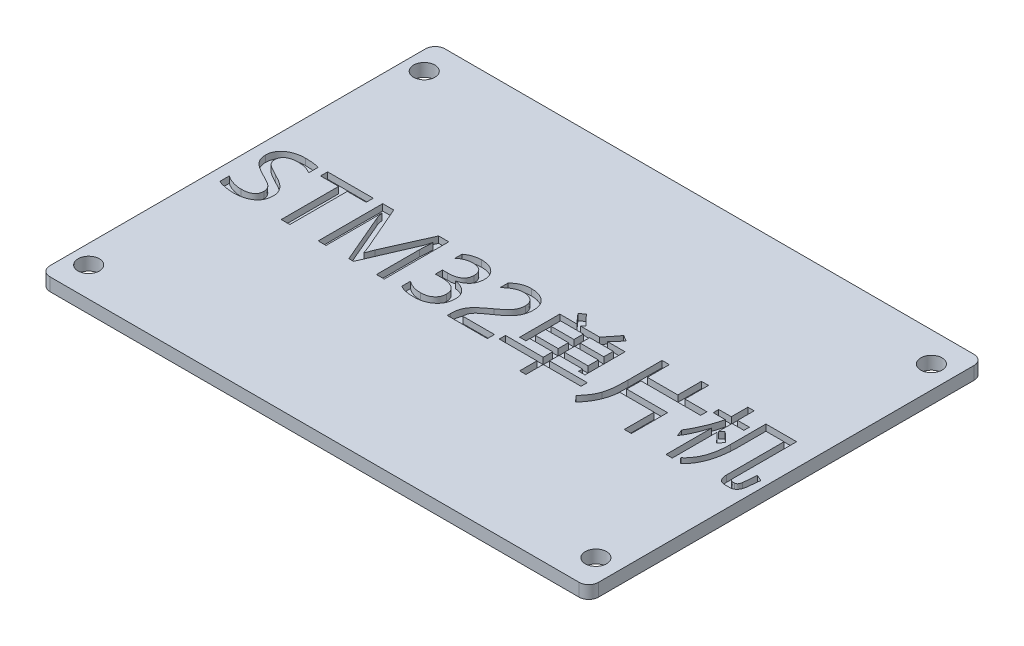
from build123d import *

# Parameters (mm, degrees)
SKETCH_1_R          = 1.65
EXTRUDE_1_DEPTH     = 2
SKETCH_2_W          = 3.658536585
SKETCH_2_H          = 1.585365854
SKETCH_2_W_2        = 3.536585366
SKETCH_2_H_2        = 1.463414634
CUT_EXTRUDE_1_DEPTH = 1


with BuildPart() as part:
    # 草图1 → 凸台-拉伸1 (new body)
    with BuildSketch(Plane(origin=(0, 0, 0), x_dir=(1, 0, 0), z_dir=(0, 1, 0))):
        with BuildLine():
            Line((41, -30.6), (-41, -30.6))
            ThreePointArc((-41, -30.6), (-42.060660172, -30.160660172), (-42.5, -29.1))
            Line((-42.5, -29.1), (-42.5, 29.1))
            ThreePointArc((-42.5, 29.1), (-42.060660172, 30.160660172), (-41, 30.6))
            Line((-41, 30.6), (41, 30.6))
            ThreePointArc((41, 30.6), (42.060660172, 30.160660172), (42.5, 29.1))
            Line((42.5, 29.1), (42.5, -29.1))
            ThreePointArc((42.5, -29.1), (42.060660172, -30.160660172), (41, -30.6))
        make_face()
        with Locations((-39.6, 26)):
            Circle(SKETCH_1_R, mode=Mode.SUBTRACT)
        with Locations((-39.6, -26)):
            Circle(SKETCH_1_R, mode=Mode.SUBTRACT)
        with Locations((39, 26)):
            Circle(SKETCH_1_R, mode=Mode.SUBTRACT)
        with Locations((39, -26)):
            Circle(SKETCH_1_R, mode=Mode.SUBTRACT)
    extrude(amount=EXTRUDE_1_DEPTH)

    # 草图2 → 切除-拉伸1 (cut)
    with BuildSketch(Plane(origin=(0, 2, 0), x_dir=(1, 0, 0), z_dir=(0, 1, 0))):
        with BuildLine():
            add(Edge.make_bspline(
                [(-40.646341463, -3.140243902), (-40.565092815, -3.203754718), (-40.397162723, -3.335023081), (-40.108905464, -3.501725879), (-39.78390449, -3.651656733), (-39.427947104, -3.781522664), (-39.05876287, -3.888750607), (-38.690356576, -3.964438153), (-38.332613597, -4.015677413), (-38.096329633, -4.021525175), (-37.980564024, -4.024390244)],
                knots=[0, 0, 0, 0, 0.000309071, 0.000638809, 0.00099601, 0.001381842, 0.001774451, 0.00214816, 0.002509545, 0.002856679, 0.002856679, 0.002856679, 0.002856679], degree=3))
            add(Edge.make_bspline(
                [(-37.980564024, -4.024390244), (-37.896064471, -4.023309527), (-37.73259623, -4.021218832), (-37.495124829, -4.004703541), (-37.27457998, -3.973588902), (-37.069965285, -3.934556547), (-36.881531596, -3.883571675), (-36.709580132, -3.8184161), (-36.552730232, -3.742816279), (-36.41237993, -3.65503561), (-36.289239167, -3.554840575), (-36.18150847, -3.444195838), (-36.091088668, -3.321092733), (-36.01789439, -3.185620713), (-35.961519557, -3.038719899), (-35.918730723, -2.880576243), (-35.893962839, -2.71039147), (-35.891506294, -2.592814705), (-35.890243902, -2.532393293)],
                knots=[0, 0, 0, 0, 0.000253494, 0.000490396, 0.000713526, 0.000921302, 0.001114998, 0.001298321, 0.00147217, 0.001636584, 0.001793715, 0.00194734, 0.002098643, 0.002250414, 0.002407879, 0.002569655, 0.002741043, 0.002922225, 0.002922225, 0.002922225, 0.002922225], degree=3))
            add(Edge.make_bspline(
                [(-35.890243902, -2.532393293), (-35.892525252, -2.464193646), (-35.897005818, -2.330249679), (-35.940963971, -2.13495639), (-36.011232602, -1.950078177), (-36.112871236, -1.778177878), (-36.236051123, -1.614951556), (-36.380847803, -1.461470071), (-36.546523643, -1.316911171), (-36.703451022, -1.206127813), (-36.847417041, -1.116201749), (-36.976898627, -1.037390398), (-37.128948402, -0.953100999), (-37.301601501, -0.858880641), (-37.496084605, -0.7561824), (-37.712096543, -0.644489552), (-37.949649275, -0.523795593), (-38.115159744, -0.441320878), (-38.20160061, -0.398246951)],
                knots=[0, 0, 0, 0, 0.000204323, 0.00040129, 0.000597333, 0.000795394, 0.000998138, 0.001209785, 0.001427219, 0.001656702, 0.001785163, 0.001936467, 0.002111367, 0.002306631, 0.002526548, 0.002771141, 0.003036169, 0.003325903, 0.003325903, 0.003325903, 0.003325903], degree=3))
            add(Edge.make_bspline(
                [(-38.20160061, -0.398246951), (-38.321413025, -0.337401977), (-38.552014603, -0.220294355), (-38.878066459, -0.039172921), (-39.172018264, 0.137658693), (-39.434702769, 0.310900845), (-39.665215196, 0.482489378), (-39.866373721, 0.648393833), (-40.033428417, 0.813432757), (-40.172428858, 0.975285656), (-40.2835505, 1.141690383), (-40.382355247, 1.309382063), (-40.463424348, 1.484641217), (-40.530904716, 1.664749203), (-40.582601766, 1.850291602), (-40.617974377, 2.041654783), (-40.642227226, 2.238331735), (-40.644959722, 2.371623007), (-40.646341463, 2.43902439)],
                knots=[0, 0, 0, 0, 0.000403104, 0.00077585, 0.001118652, 0.001432046, 0.001719396, 0.001980447, 0.002213549, 0.002423126, 0.002619206, 0.002813014, 0.003006522, 0.003197651, 0.00338951, 0.003583468, 0.003781061, 0.003983186, 0.003983186, 0.003983186, 0.003983186], degree=3))
            add(Edge.make_bspline(
                [(-40.646341463, 2.43902439), (-40.643766103, 2.539594107), (-40.638731283, 2.736207562), (-40.588931134, 3.022548528), (-40.511607036, 3.29370703), (-40.400195209, 3.54842188), (-40.257584542, 3.786839099), (-40.084456207, 4.00970024), (-39.879277735, 4.216578969), (-39.642706957, 4.402873339), (-39.384660616, 4.572351656), (-39.106939905, 4.718228918), (-38.814841679, 4.845978701), (-38.504552764, 4.945015052), (-38.179724932, 5.026942495), (-37.837111043, 5.079946424), (-37.47891765, 5.115892832), (-37.234341564, 5.119906621), (-37.109756098, 5.12195122)],
                knots=[0, 0, 0, 0, 0.000301453, 0.000589339, 0.000869141, 0.001145621, 0.001420777, 0.00170054, 0.001990231, 0.00229258, 0.002602284, 0.002915121, 0.003232629, 0.003557419, 0.003891091, 0.004236621, 0.004596491, 0.004970141, 0.004970141, 0.004970141, 0.004970141], degree=3))
            add(Edge.make_bspline(
                [(-37.109756098, 5.12195122), (-36.989057483, 5.121488508), (-36.75647164, 5.120596863), (-36.419761549, 5.106269432), (-36.107580242, 5.08675997), (-35.820400358, 5.055853646), (-35.558076698, 5.019180351), (-35.321221261, 4.97051321), (-35.107472183, 4.918298435), (-34.976533877, 4.870267231), (-34.914634146, 4.847560976)],
                knots=[0, 0, 0, 0, 0.000362063, 0.000697694, 0.001010896, 0.001300235, 0.001564054, 0.001805089, 0.002025542, 0.002223199, 0.002223199, 0.002223199, 0.002223199], degree=3))
            Line((-34.914634146, 4.847560976), (-34.914634146, 3.384146341))
            add(Edge.make_bspline(
                [(-34.914634146, 3.384146341), (-34.991763566, 3.435995535), (-35.147236384, 3.540510002), (-35.400514973, 3.667658694), (-35.665992663, 3.779925293), (-35.947689339, 3.868456562), (-36.243584534, 3.939759236), (-36.554661298, 3.987715937), (-36.880420231, 4.019877291), (-37.102687228, 4.022862266), (-37.216463415, 4.024390244)],
                knots=[0, 0, 0, 0, 0.000278553, 0.000561491, 0.000848487, 0.001142562, 0.001446211, 0.001760732, 0.002086097, 0.002427312, 0.002427312, 0.002427312, 0.002427312], degree=3))
            add(Edge.make_bspline(
                [(-37.216463415, 4.024390244), (-37.29146859, 4.023583296), (-37.43855817, 4.022000822), (-37.653982901, 4.001028754), (-37.859346452, 3.974546457), (-38.053651623, 3.932099459), (-38.236827917, 3.87649597), (-38.410409181, 3.810344858), (-38.5729348, 3.731925896), (-38.723660407, 3.6432583), (-38.85910775, 3.542309741), (-38.978337949, 3.431374833), (-39.079622132, 3.311238974), (-39.163836349, 3.181926091), (-39.225653121, 3.041789193), (-39.272862968, 2.893188266), (-39.299012324, 2.734657715), (-39.302900331, 2.625850283), (-39.304878049, 2.570503049)],
                knots=[0, 0, 0, 0, 0.00022492, 0.000441082, 0.00064885, 0.000845817, 0.001036908, 0.001222691, 0.001402515, 0.001577674, 0.001746501, 0.001908277, 0.002065153, 0.002216852, 0.002369505, 0.002523189, 0.002683579, 0.00284963, 0.00284963, 0.00284963, 0.00284963], degree=3))
            add(Edge.make_bspline(
                [(-39.304878049, 2.570503049), (-39.30403905, 2.520882548), (-39.302397437, 2.423793391), (-39.281887693, 2.281758044), (-39.252873297, 2.146604428), (-39.208095495, 2.018903541), (-39.150251293, 1.898779634), (-39.082542686, 1.784334863), (-39.000743154, 1.678125064), (-38.904840805, 1.576095189), (-38.785923272, 1.475321149), (-38.64236707, 1.367245867), (-38.47124582, 1.248367877), (-38.26723707, 1.126599314), (-38.03794201, 0.990319995), (-37.777694822, 0.848584099), (-37.490184252, 0.695053368), (-37.286611803, 0.59396847), (-37.180259146, 0.541158537)],
                knots=[0, 0, 0, 0, 0.000148738, 0.000291026, 0.000429708, 0.000562888, 0.000695849, 0.000829179, 0.000961044, 0.00109719, 0.001248481, 0.001427982, 0.00163623, 0.001873162, 0.002140488, 0.002436428, 0.002762044, 0.003118248, 0.003118248, 0.003118248, 0.003118248], degree=3))
            add(Edge.make_bspline(
                [(-37.180259146, 0.541158537), (-37.062210434, 0.48442066), (-36.833483335, 0.374487314), (-36.510238002, 0.19748544), (-36.211115989, 0.025476285), (-35.941738613, -0.150042975), (-35.697421523, -0.322344733), (-35.48453268, -0.498650495), (-35.295254648, -0.671542052), (-35.134380572, -0.84838835), (-34.994990646, -1.027171885), (-34.877340492, -1.211007711), (-34.774105769, -1.398421334), (-34.693447919, -1.593273964), (-34.627231361, -1.792242827), (-34.581725476, -1.997168499), (-34.554618181, -2.207728666), (-34.550739219, -2.350022122), (-34.548780488, -2.421875)],
                knots=[0, 0, 0, 0, 0.000392854, 0.000761181, 0.001105315, 0.00142772, 0.001725428, 0.002001612, 0.002256442, 0.002493826, 0.002717938, 0.002935697, 0.003147995, 0.003358919, 0.003567412, 0.003776365, 0.003987659, 0.00420319, 0.00420319, 0.00420319, 0.00420319], degree=3))
            add(Edge.make_bspline(
                [(-34.548780488, -2.421875), (-34.55177457, -2.52745334), (-34.557627311, -2.733834715), (-34.601259088, -3.033844529), (-34.676175624, -3.314263726), (-34.778940668, -3.577003626), (-34.915205876, -3.818780436), (-35.079256937, -4.042956243), (-35.272335632, -4.248250709), (-35.497435317, -4.429807972), (-35.745242067, -4.595204415), (-36.019324207, -4.734563839), (-36.314408486, -4.856549257), (-36.633720313, -4.95100294), (-36.974183111, -5.031530344), (-37.33909977, -5.08212742), (-37.726507049, -5.115552768), (-37.992555389, -5.119780135), (-38.129192073, -5.12195122)],
                knots=[0, 0, 0, 0, 0.000316678, 0.000619033, 0.000906989, 0.001185816, 0.001463062, 0.001737088, 0.002017461, 0.002305845, 0.002602857, 0.002909664, 0.003226714, 0.003559439, 0.003907497, 0.004275335, 0.004663503, 0.005073342, 0.005073342, 0.005073342, 0.005073342], degree=3))
            add(Edge.make_bspline(
                [(-38.129192073, -5.12195122), (-38.231515576, -5.119989954), (-38.444781396, -5.115902224), (-38.775916109, -5.08486106), (-39.131992559, -5.039366013), (-39.499241215, -4.975905983), (-39.85430453, -4.903913084), (-40.166260463, -4.812619903), (-40.430224711, -4.723294948), (-40.57861599, -4.641149534), (-40.646341463, -4.603658537)],
                knots=[0, 0, 0, 0, 0.000306931, 0.000639716, 0.000997075, 0.00138364, 0.001757742, 0.002082822, 0.002358927, 0.00259074, 0.00259074, 0.00259074, 0.00259074], degree=3))
            Line((-40.646341463, -4.603658537), (-40.646341463, -3.140243902))
        make_face()
        Polygon((-26.5, 3.902439024), (-29.426829268, 3.902439024), (-29.426829268, -5), (-30.768292683, -5), (-30.768292683, 3.902439024), (-33.573170732, 3.902439024), (-33.573170732, 5), (-26.5, 5), align=None)
        with BuildLine():
            Line((-16.012195122, -5), (-16.012195122, 1.67492378))
            add(Edge.make_bspline(
                [(-16.012195122, 1.67492378), (-16.011130759, 1.819125436), (-16.008893357, 2.122252609), (-15.987889718, 2.597406491), (-15.957789989, 3.114517134), (-15.929644467, 3.472478618), (-15.915015244, 3.658536585)],
                knots=[0, 0, 0, 0, 0.000432584, 0.000909336, 0.001426623, 0.001986502, 0.001986502, 0.001986502, 0.001986502], degree=3))
            Line((-15.915015244, 3.658536585), (-15.947408537, 3.658536585))
            add(Edge.make_bspline(
                [(-15.947408537, 3.658536585), (-15.974075928, 3.545946886), (-16.023047364, 3.339189527), (-16.099264489, 3.057521965), (-16.169097487, 2.830338969), (-16.221721157, 2.699817743), (-16.244664634, 2.642911585)],
                knots=[0, 0, 0, 0, 0.000347081, 0.000637373, 0.000875406, 0.001059412, 0.001059412, 0.001059412, 0.001059412], degree=3))
            Line((-16.244664634, 2.642911585), (-19.548780488, -5))
            Line((-19.548780488, -5), (-20.280487805, -5))
            Line((-20.280487805, -5), (-23.523628049, 2.585746951))
            add(Edge.make_bspline(
                [(-23.523628049, 2.585746951), (-23.534142357, 2.610385448), (-23.557040224, 2.664042713), (-23.586584822, 2.755757921), (-23.62124036, 2.863426779), (-23.656856308, 2.989404111), (-23.695589832, 3.132024776), (-23.732298807, 3.29275747), (-23.775133859, 3.46960231), (-23.802680724, 3.593699412), (-23.817073171, 3.658536585)],
                knots=[0, 0, 0, 0, 8.0325e-05, 0.00017493, 0.00028883, 0.000419699, 0.000567605, 0.00073214, 0.000914242, 0.001113481, 0.001113481, 0.001113481, 0.001113481], degree=3))
            Line((-23.817073171, 3.658536585), (-23.855182927, 3.658536585))
            add(Edge.make_bspline(
                [(-23.855182927, 3.658536585), (-23.851828482, 3.596934372), (-23.844741587, 3.466788102), (-23.837323094, 3.260963113), (-23.832371291, 3.035441545), (-23.8257615, 2.78966192), (-23.822967272, 2.524768035), (-23.818383723, 2.239596748), (-23.816708778, 1.934707014), (-23.816949046, 1.724466376), (-23.817073171, 1.615853659)],
                knots=[0, 0, 0, 0, 0.000185078, 0.000391011, 0.000617837, 0.000861806, 0.001128602, 0.001412545, 0.001717429, 0.002043267, 0.002043267, 0.002043267, 0.002043267], degree=3))
            Line((-23.817073171, 1.615853659), (-23.817073171, -5))
            Line((-23.817073171, -5), (-25.036585366, -5))
            Line((-25.036585366, -5), (-25.036585366, 5))
            Line((-25.036585366, 5), (-23.329268293, 5))
            Line((-23.329268293, 5), (-20.370045732, -1.827362805))
            add(Edge.make_bspline(
                [(-20.370045732, -1.827362805), (-20.317944598, -1.95095613), (-20.220616424, -2.181836186), (-20.093994397, -2.50875498), (-19.994678845, -2.791714707), (-19.946185827, -2.968492643), (-19.924161585, -3.048780488)],
                knots=[0, 0, 0, 0, 0.000402351, 0.000751617, 0.001051706, 0.001301405, 0.001301405, 0.001301405, 0.001301405], degree=3))
            Line((-19.924161585, -3.048780488), (-19.878429878, -3.048780488))
            add(Edge.make_bspline(
                [(-19.878429878, -3.048780488), (-19.851033144, -2.975133024), (-19.798623949, -2.834247464), (-19.724842968, -2.631832189), (-19.655664717, -2.448485819), (-19.593505935, -2.283063475), (-19.535792241, -2.136797805), (-19.486477432, -2.008157522), (-19.442621955, -1.898535018), (-19.416011713, -1.831181553), (-19.403963415, -1.800685976)],
                knots=[0, 0, 0, 0, 0.000235734, 0.000450953, 0.000646319, 0.000823622, 0.000981087, 0.00111803, 0.001236921, 0.00133529, 0.00133529, 0.00133529, 0.00133529], degree=3))
            Line((-19.403963415, -1.800685976), (-16.37804878, 5))
            Line((-16.37804878, 5), (-14.792682927, 5))
            Line((-14.792682927, 5), (-14.792682927, -5))
            Line((-14.792682927, -5), (-16.012195122, -5))
        make_face()
        with BuildLine():
            add(Edge.make_bspline(
                [(-12.475609756, -3.262195122), (-12.390913822, -3.323505259), (-12.222942279, -3.445097381), (-11.954287323, -3.597996573), (-11.679456815, -3.731558038), (-11.394938699, -3.836919532), (-11.10370198, -3.922712092), (-10.80373545, -3.980290084), (-10.49553292, -4.018622972), (-10.286958009, -4.022452299), (-10.181402439, -4.024390244)],
                knots=[0, 0, 0, 0, 0.000313457, 0.000621658, 0.000925922, 0.00122923, 0.001530755, 0.001835692, 0.002144605, 0.002461122, 0.002461122, 0.002461122, 0.002461122], degree=3))
            add(Edge.make_bspline(
                [(-10.181402439, -4.024390244), (-10.098138758, -4.023010268), (-9.93572929, -4.020318564), (-9.699493659, -3.997039625), (-9.476178935, -3.95978178), (-9.26692959, -3.903800079), (-9.069584013, -3.835652471), (-8.885281113, -3.752681287), (-8.717255589, -3.649465193), (-8.559905173, -3.53621309), (-8.419861219, -3.407612328), (-8.298800196, -3.26679976), (-8.194828158, -3.117016563), (-8.107919419, -2.956657882), (-8.043543472, -2.783821871), (-7.998426821, -2.60153028), (-7.968371929, -2.409522887), (-7.965093428, -2.277810619), (-7.963414634, -2.210365854)],
                knots=[0, 0, 0, 0, 0.000249735, 0.00048712, 0.000711417, 0.000928183, 0.001136091, 0.001337316, 0.001533063, 0.001726674, 0.001918173, 0.002101912, 0.002282682, 0.002464264, 0.002647588, 0.002834296, 0.003026977, 0.003229183, 0.003229183, 0.003229183, 0.003229183], degree=3))
            add(Edge.make_bspline(
                [(-7.963414634, -2.210365854), (-7.965872937, -2.135967004), (-7.970663722, -1.990977211), (-8.000226026, -1.780229945), (-8.054506629, -1.584140944), (-8.127801388, -1.40215279), (-8.225616272, -1.235909953), (-8.341611466, -1.082595292), (-8.480360326, -0.944474404), (-8.640760662, -0.82148802), (-8.822072942, -0.713728411), (-9.024173166, -0.619086281), (-9.248030878, -0.543523647), (-9.490881266, -0.474485118), (-9.756626408, -0.427534425), (-10.042697041, -0.390742102), (-10.35006711, -0.370478052), (-10.561838327, -0.367427665), (-10.671112805, -0.365853659)],
                knots=[0, 0, 0, 0, 0.000223235, 0.000435044, 0.000636594, 0.000832276, 0.001021831, 0.001213529, 0.001407552, 0.001607265, 0.001818371, 0.002039161, 0.002275395, 0.002526414, 0.00279587, 0.003083977, 0.003391476, 0.003719309, 0.003719309, 0.003719309, 0.003719309], degree=3))
            Line((-10.671112805, -0.365853659), (-11.5, -0.365853659))
            Line((-11.5, -0.365853659), (-11.5, 0.731707317))
            Line((-11.5, 0.731707317), (-10.713033537, 0.731707317))
            add(Edge.make_bspline(
                [(-10.713033537, 0.731707317), (-10.617105385, 0.73348268), (-10.430774952, 0.736931137), (-10.160146492, 0.754540492), (-9.908480589, 0.789901244), (-9.674181761, 0.833923058), (-9.459814066, 0.89527538), (-9.262646235, 0.967163744), (-9.084894998, 1.054600976), (-8.926199598, 1.156824616), (-8.782533285, 1.268025495), (-8.66292996, 1.398178876), (-8.557498699, 1.537918369), (-8.473997423, 1.693731358), (-8.408619985, 1.862705775), (-8.364198226, 2.044706942), (-8.334029877, 2.239221925), (-8.330890205, 2.373479652), (-8.329268293, 2.442835366)],
                knots=[0, 0, 0, 0, 0.00028783, 0.000559079, 0.000812931, 0.001049856, 0.001273644, 0.001481053, 0.001678756, 0.001866405, 0.002046744, 0.002221986, 0.002395008, 0.002570655, 0.002750418, 0.002937127, 0.003131692, 0.003339608, 0.003339608, 0.003339608, 0.003339608], degree=3))
            add(Edge.make_bspline(
                [(-8.329268293, 2.442835366), (-8.330826262, 2.50703763), (-8.333842972, 2.631353107), (-8.354314365, 2.811398597), (-8.39091087, 2.978412875), (-8.440407532, 3.133580014), (-8.502737466, 3.277498028), (-8.58118841, 3.4085646), (-8.676715041, 3.525176772), (-8.782151763, 3.632800076), (-8.904879022, 3.725060468), (-9.040744426, 3.804684357), (-9.190290273, 3.874311916), (-9.355031857, 3.928190285), (-9.533148047, 3.972951967), (-9.725886628, 4.001803379), (-9.932622872, 4.02201979), (-10.075275564, 4.023582512), (-10.149009146, 4.024390244)],
                knots=[0, 0, 0, 0, 0.000192605, 0.000372943, 0.000542628, 0.000704729, 0.000860863, 0.001012166, 0.001161258, 0.001312164, 0.001463083, 0.001620272, 0.001783966, 0.001956904, 0.002139454, 0.002334308, 0.002540981, 0.002762091, 0.002762091, 0.002762091, 0.002762091], degree=3))
            add(Edge.make_bspline(
                [(-10.149009146, 4.024390244), (-10.235535832, 4.022435295), (-10.407456552, 4.018550988), (-10.662989539, 3.979718468), (-10.914840076, 3.922133063), (-11.162148233, 3.836089875), (-11.406958235, 3.729888068), (-11.646677395, 3.597455507), (-11.883372386, 3.442353141), (-12.033178154, 3.323136479), (-12.109756098, 3.262195122)],
                knots=[0, 0, 0, 0, 0.000259398, 0.000515401, 0.000773769, 0.001033482, 0.001299705, 0.00157344, 0.001854071, 0.002147541, 0.002147541, 0.002147541, 0.002147541], degree=3))
            Line((-12.109756098, 3.262195122), (-12.109756098, 4.359756098))
            add(Edge.make_bspline(
                [(-12.109756098, 4.359756098), (-12.02764482, 4.421079281), (-11.864482466, 4.542933857), (-11.601061932, 4.696513746), (-11.329249736, 4.828444156), (-11.04663832, 4.935613142), (-10.754331025, 5.020352668), (-10.450591246, 5.078035958), (-10.137276791, 5.116151335), (-9.924911047, 5.120002524), (-9.817454268, 5.12195122)],
                knots=[0, 0, 0, 0, 0.000307233, 0.000610499, 0.000913046, 0.001212789, 0.001516145, 0.001824822, 0.002139413, 0.002461643, 0.002461643, 0.002461643, 0.002461643], degree=3))
            add(Edge.make_bspline(
                [(-9.817454268, 5.12195122), (-9.713188171, 5.120584221), (-9.509833008, 5.117918097), (-9.213165186, 5.083724754), (-8.932260461, 5.032819887), (-8.665666856, 4.963255694), (-8.415522547, 4.869746939), (-8.18190147, 4.754422788), (-7.963069014, 4.620751188), (-7.761574203, 4.467188394), (-7.581281749, 4.295627222), (-7.421875518, 4.112624375), (-7.286809176, 3.916766792), (-7.177908055, 3.707102851), (-7.091980596, 3.486075583), (-7.030649033, 3.252846988), (-6.993589165, 3.007424436), (-6.98976062, 2.839308728), (-6.987804878, 2.753429878)],
                knots=[0, 0, 0, 0, 0.000312645, 0.000609767, 0.000894559, 0.001168645, 0.001435155, 0.001694217, 0.001949125, 0.002203328, 0.002452685, 0.002694501, 0.002930228, 0.003164611, 0.003401697, 0.003640187, 0.003886762, 0.004144257, 0.004144257, 0.004144257, 0.004144257], degree=3))
            add(Edge.make_bspline(
                [(-6.987804878, 2.753429878), (-6.989011961, 2.674594612), (-6.99137407, 2.520324025), (-7.017427271, 2.294290809), (-7.056773029, 2.078880201), (-7.112009255, 1.873351296), (-7.183903782, 1.679276977), (-7.273506527, 1.496471886), (-7.374643676, 1.322407807), (-7.497036863, 1.16203518), (-7.632071699, 1.010214252), (-7.785387702, 0.871279418), (-7.95433538, 0.74354667), (-8.137663477, 0.624322107), (-8.338756313, 0.518664452), (-8.554156382, 0.421186281), (-8.785759448, 0.334664101), (-8.947561987, 0.288514864), (-9.030487805, 0.264862805)],
                knots=[0, 0, 0, 0, 0.000236403, 0.000462611, 0.000681618, 0.000892861, 0.001100271, 0.001301397, 0.001503027, 0.001703104, 0.001905498, 0.002111864, 0.002322616, 0.002540376, 0.002767129, 0.003003363, 0.003249356, 0.003507976, 0.003507976, 0.003507976, 0.003507976], degree=3))
            Line((-9.030487805, 0.264862805), (-9.030487805, 0.240091463))
            add(Edge.make_bspline(
                [(-9.030487805, 0.240091463), (-8.940121518, 0.228543095), (-8.762872738, 0.20589157), (-8.505205172, 0.152989145), (-8.26239656, 0.081399433), (-8.032612816, -0.002169754), (-7.82045025, -0.109337251), (-7.62081652, -0.228376103), (-7.437568326, -0.367144381), (-7.267984579, -0.518862377), (-7.115273931, -0.684154535), (-6.983336629, -0.861947929), (-6.87248799, -1.050114048), (-6.779978979, -1.246869099), (-6.709881212, -1.454227486), (-6.657807248, -1.67089451), (-6.626843159, -1.898235352), (-6.62359971, -2.053385457), (-6.62195122, -2.132240854)],
                knots=[0, 0, 0, 0, 0.00027325, 0.000535965, 0.000788023, 0.001032231, 0.001268281, 0.001499976, 0.001728634, 0.001956665, 0.002181875, 0.002402534, 0.002619525, 0.002836056, 0.003053591, 0.003274972, 0.003503765, 0.003740238, 0.003740238, 0.003740238, 0.003740238], degree=3))
            add(Edge.make_bspline(
                [(-6.62195122, -2.132240854), (-6.624728188, -2.241657258), (-6.630162319, -2.455769559), (-6.677226524, -2.76875001), (-6.753213798, -3.065913341), (-6.859964161, -3.347550101), (-6.99839478, -3.611720516), (-7.165534412, -3.860469427), (-7.364991285, -4.091388391), (-7.593637711, -4.304035058), (-7.846717883, -4.495666425), (-8.120366118, -4.665069127), (-8.415610629, -4.805266732), (-8.729562843, -4.922753076), (-9.064903089, -5.011273074), (-9.419678442, -5.076006555), (-9.794390088, -5.114176505), (-10.050471243, -5.119320935), (-10.181402439, -5.12195122)],
                knots=[0, 0, 0, 0, 0.000328098, 0.000642041, 0.000947068, 0.001246812, 0.001543408, 0.001839893, 0.002143919, 0.002456697, 0.002774919, 0.003094866, 0.003420431, 0.003753848, 0.004099125, 0.004459418, 0.004834833, 0.00522759, 0.00522759, 0.00522759, 0.00522759], degree=3))
            add(Edge.make_bspline(
                [(-10.181402439, -5.12195122), (-10.29705559, -5.120757932), (-10.522926109, -5.118427442), (-10.85293926, -5.092426004), (-11.166234106, -5.053868339), (-11.461949488, -4.996067682), (-11.741380312, -4.924840288), (-12.002648665, -4.834347252), (-12.24872057, -4.73130151), (-12.400755195, -4.645770101), (-12.475609756, -4.603658537)],
                knots=[0, 0, 0, 0, 0.000346883, 0.000677461, 0.000992513, 0.001293345, 0.001580815, 0.001856801, 0.002122267, 0.002379733, 0.002379733, 0.002379733, 0.002379733], degree=3))
            Line((-12.475609756, -4.603658537), (-12.475609756, -3.262195122))
        make_face()
        with BuildLine():
            add(Edge.make_bspline(
                [(-0.280487805, 2.345655488), (-0.281696861, 2.409267368), (-0.284064299, 2.533824984), (-0.310000033, 2.714892269), (-0.34879567, 2.885900615), (-0.407218446, 3.045149004), (-0.479428318, 3.195335215), (-0.569551623, 3.33438962), (-0.674883338, 3.463682693), (-0.797725556, 3.579249423), (-0.932888898, 3.684078565), (-1.079969616, 3.776224697), (-1.239544335, 3.852291377), (-1.409891421, 3.915108453), (-1.592013434, 3.965421401), (-1.786152535, 3.998196835), (-1.991757577, 4.020032631), (-2.132561717, 4.022909555), (-2.205030488, 4.024390244)],
                knots=[0, 0, 0, 0, 0.000190701, 0.00037341, 0.000547655, 0.000715824, 0.000881152, 0.00104659, 0.001211764, 0.001380235, 0.001551369, 0.001724265, 0.001899829, 0.002080699, 0.002268378, 0.002465741, 0.002670702, 0.002888062, 0.002888062, 0.002888062, 0.002888062], degree=3))
            add(Edge.make_bspline(
                [(-2.205030488, 4.024390244), (-2.310103775, 4.020789931), (-2.522517694, 4.013511614), (-2.841040591, 3.951036123), (-3.161119794, 3.851352394), (-3.479421, 3.711274788), (-3.794369693, 3.537970917), (-4.099714858, 3.329110615), (-4.395169426, 3.086215917), (-4.577639343, 2.902445088), (-4.670731707, 2.808689024)],
                knots=[0, 0, 0, 0, 0.000314982, 0.000636762, 0.000970048, 0.001319085, 0.001678137, 0.002047039, 0.002427398, 0.002823565, 0.002823565, 0.002823565, 0.002823565], degree=3))
            Line((-4.670731707, 2.808689024), (-4.670731707, 4.032012195))
            add(Edge.make_bspline(
                [(-4.670731707, 4.032012195), (-4.587058978, 4.116109927), (-4.421493233, 4.282516638), (-4.150378075, 4.503123115), (-3.859433022, 4.688177242), (-3.552637587, 4.847089582), (-3.222488957, 4.972126832), (-2.866053816, 5.058704042), (-2.483660465, 5.113414994), (-2.219198941, 5.119050564), (-2.083079268, 5.12195122)],
                knots=[0, 0, 0, 0, 0.00035575, 0.000703933, 0.001045914, 0.001388499, 0.001738866, 0.002102115, 0.002486929, 0.002895064, 0.002895064, 0.002895064, 0.002895064], degree=3))
            add(Edge.make_bspline(
                [(-2.083079268, 5.12195122), (-1.972455636, 5.119915062), (-1.755738936, 5.115926136), (-1.439358993, 5.080070254), (-1.138468361, 5.026938639), (-0.85593586, 4.9454863), (-0.588281876, 4.845289736), (-0.338842864, 4.718534096), (-0.104469568, 4.571680239), (0.110487128, 4.402050272), (0.30466663, 4.213766093), (0.476203585, 4.009150498), (0.619653866, 3.786792623), (0.736129384, 3.548510432), (0.828753757, 3.295232922), (0.892737789, 3.025361674), (0.931401371, 2.739308332), (0.936440809, 2.543315498), (0.93902439, 2.442835366)],
                knots=[0, 0, 0, 0, 0.000331752, 0.000649917, 0.000954139, 0.001247287, 0.001530751, 0.001810261, 0.00208516, 0.002359245, 0.0026301, 0.002895298, 0.003158511, 0.003421834, 0.003689472, 0.003965846, 0.00425231, 0.004553673, 0.004553673, 0.004553673, 0.004553673], degree=3))
            add(Edge.make_bspline(
                [(0.93902439, 2.442835366), (0.937815719, 2.352573096), (0.93542769, 2.174237732), (0.908885507, 1.91226812), (0.872025802, 1.658618512), (0.816794358, 1.41456049), (0.743967806, 1.179814882), (0.65631253, 0.954282407), (0.553152563, 0.738347252), (0.433615425, 0.529912651), (0.294245607, 0.325868248), (0.134162421, 0.121863837), (-0.05020432, -0.081402076), (-0.254538785, -0.288511981), (-0.483067182, -0.494915385), (-0.733763164, -0.702261089), (-1.004165507, -0.913592835), (-1.196981308, -1.047678837), (-1.296112805, -1.116615854)],
                knots=[0, 0, 0, 0, 0.000270687, 0.000534808, 0.000789203, 0.001039287, 0.001284592, 0.001525921, 0.001764564, 0.002001856, 0.002246026, 0.002505236, 0.002779156, 0.003068846, 0.003377753, 0.003702481, 0.004044748, 0.004406916, 0.004406916, 0.004406916, 0.004406916], degree=3))
            add(Edge.make_bspline(
                [(-1.296112805, -1.116615854), (-1.396001709, -1.185608149), (-1.588116262, -1.318299805), (-1.861086968, -1.512517898), (-2.109431, -1.689488408), (-2.331550045, -1.851540014), (-2.526620841, -2.000501621), (-2.698712028, -2.131040206), (-2.84376339, -2.247094681), (-2.998447514, -2.378781334), (-3.159974013, -2.532214279), (-3.325286712, -2.712532189), (-3.458428164, -2.890087524), (-3.561315632, -3.067599955), (-3.63521064, -3.253384482), (-3.689182751, -3.452616383), (-3.718554412, -3.671646806), (-3.723199552, -3.823597177), (-3.725609756, -3.902439024)],
                knots=[0, 0, 0, 0, 0.000364193, 0.000700445, 0.001005019, 0.001279045, 0.001525237, 0.001741331, 0.001927026, 0.002082449, 0.002350663, 0.002594841, 0.002815499, 0.003015212, 0.00320841, 0.003413637, 0.003632992, 0.003869549, 0.003869549, 0.003869549, 0.003869549], degree=3))
            Line((-3.725609756, -3.902439024), (1.182926829, -3.902439024))
            Line((1.182926829, -3.902439024), (1.182926829, -5))
            Line((1.182926829, -5), (-5.036585366, -5))
            Line((-5.036585366, -5), (-5.036585366, -4.504573171))
            add(Edge.make_bspline(
                [(-5.036585366, -4.504573171), (-5.03366245, -4.366631634), (-5.028016315, -4.100172895), (-4.9849126, -3.716654852), (-4.91093812, -3.365622932), (-4.807394391, -3.042180058), (-4.665799402, -2.73786848), (-4.487449725, -2.443278007), (-4.272570442, -2.151149071), (-4.060693726, -1.916288439), (-3.87123859, -1.722238247), (-3.704289464, -1.571551838), (-3.521339205, -1.409951857), (-3.317185375, -1.243985999), (-3.0966028, -1.067862855), (-2.855381574, -0.886707125), (-2.594852369, -0.699036288), (-2.414132665, -0.572092866), (-2.321265244, -0.506859756)],
                knots=[0, 0, 0, 0, 0.000413772, 0.000799274, 0.001155809, 0.001488436, 0.001815825, 0.00216026, 0.002520029, 0.002902026, 0.00310818, 0.00333339, 0.003576458, 0.003840442, 0.004122557, 0.004423244, 0.004745322, 0.005085786, 0.005085786, 0.005085786, 0.005085786], degree=3))
            add(Edge.make_bspline(
                [(-2.321265244, -0.506859756), (-2.226144621, -0.440190977), (-2.042278805, -0.311321872), (-1.783691667, -0.113907701), (-1.545499947, 0.073895336), (-1.333952426, 0.25853702), (-1.142571379, 0.4338651), (-0.97762428, 0.605368946), (-0.833318038, 0.76911817), (-0.710947535, 0.92912695), (-0.60838228, 1.090126712), (-0.520813316, 1.254005531), (-0.445989998, 1.422644703), (-0.384119152, 1.596260203), (-0.339702596, 1.776598974), (-0.303978376, 1.961451287), (-0.28591276, 2.152211565), (-0.282305499, 2.280839843), (-0.280487805, 2.345655488)],
                knots=[0, 0, 0, 0, 0.000348433, 0.000673513, 0.000975862, 0.001258189, 0.001515712, 0.001754234, 0.001971668, 0.002170223, 0.002357873, 0.002543714, 0.002727126, 0.002910934, 0.003095796, 0.003283784, 0.003475283, 0.003669792, 0.003669792, 0.003669792, 0.003669792], degree=3))
        make_face()
        with BuildLine():
            Line((2.158536585, -3.170731707), (8.012195122, -3.170731707))
            Line((8.012195122, -3.170731707), (8.012195122, -1.707317073))
            Line((8.012195122, -1.707317073), (4.475609756, -1.707317073))
            Line((4.475609756, -1.707317073), (4.475609756, -2.317073171))
            Line((4.475609756, -2.317073171), (3.5, -2.317073171))
            Line((3.5, -2.317073171), (3.5, 3.902439024))
            Line((3.5, 3.902439024), (6.141006098, 3.902439024))
            add(Edge.make_bspline(
                [(6.141006098, 3.902439024), (5.934052547, 4.1450206), (5.509647389, 4.642489098), (5.067834292, 5.124568222), (4.841463415, 5.371570122)],
                knots=[0, 0, 0, 0, 0.000956517, 0.001961555, 0.001961555, 0.001961555, 0.001961555], degree=3))
            Line((4.841463415, 5.371570122), (5.542682927, 5.975609756))
            add(Edge.make_bspline(
                [(5.542682927, 5.975609756), (5.691492896, 5.827166191), (5.981487284, 5.537885837), (6.4020561, 5.112262402), (6.789995774, 4.699885012), (7.038105255, 4.42985295), (7.158536585, 4.298780488)],
                knots=[0, 0, 0, 0, 0.000630575, 0.001228838, 0.00179497, 0.002328969, 0.002328969, 0.002328969, 0.002328969], degree=3))
            Line((7.158536585, 4.298780488), (6.739329268, 3.902439024))
            Line((6.739329268, 3.902439024), (9.68902439, 3.902439024))
            add(Edge.make_bspline(
                [(9.68902439, 3.902439024), (9.825511153, 4.064575574), (10.101904512, 4.392911192), (10.512035018, 4.901324433), (10.924918085, 5.429873665), (11.19746337, 5.792253022), (11.335365854, 5.975609756)],
                knots=[0, 0, 0, 0, 0.000635794, 0.001287518, 0.001959518, 0.002647787, 0.002647787, 0.002647787, 0.002647787], degree=3))
            Line((11.335365854, 5.975609756), (12.280487805, 5.421112805))
            add(Edge.make_bspline(
                [(12.280487805, 5.421112805), (12.163161722, 5.286937434), (11.93212316, 5.022719248), (11.587333753, 4.634621634), (11.245747444, 4.263993389), (11.019805824, 4.021740874), (10.908536585, 3.902439024)],
                knots=[0, 0, 0, 0, 0.000534713, 0.001052956, 0.001557339, 0.002046752, 0.002046752, 0.002046752, 0.002046752], degree=3))
            Line((10.908536585, 3.902439024), (13.62195122, 3.902439024))
            Line((13.62195122, 3.902439024), (13.62195122, -2.317073171))
            Line((13.62195122, -2.317073171), (12.646341463, -2.317073171))
            Line((12.646341463, -2.317073171), (12.646341463, -1.707317073))
            Line((12.646341463, -1.707317073), (8.987804878, -1.707317073))
            Line((8.987804878, -1.707317073), (8.987804878, -3.170731707))
            Line((8.987804878, -3.170731707), (14.841463415, -3.170731707))
            Line((14.841463415, -3.170731707), (14.841463415, -4.146341463))
            Line((14.841463415, -4.146341463), (8.987804878, -4.146341463))
            Line((8.987804878, -4.146341463), (8.987804878, -6.829268293))
            Line((8.987804878, -6.829268293), (8.012195122, -6.829268293))
            Line((8.012195122, -6.829268293), (8.012195122, -4.146341463))
            Line((8.012195122, -4.146341463), (2.158536585, -4.146341463))
            Line((2.158536585, -4.146341463), (2.158536585, -3.170731707))
        make_face()
        with Locations((10.817073171, -0.06097561)):
            Rectangle(SKETCH_2_W, SKETCH_2_H, mode=Mode.SUBTRACT)
        with Locations((6.243902439, -0.06097561)):
            Rectangle(SKETCH_2_W_2, SKETCH_2_H, mode=Mode.SUBTRACT)
        with Locations((10.817073171, 2.317073171)):
            Rectangle(SKETCH_2_W, SKETCH_2_H_2, mode=Mode.SUBTRACT)
        with Locations((6.243902439, 2.317073171)):
            Rectangle(SKETCH_2_W_2, SKETCH_2_H_2, mode=Mode.SUBTRACT)
        with BuildLine():
            Line((17.646341463, 5.609756098), (18.782012195, 5.609756098))
            Line((18.782012195, 5.609756098), (18.782012195, 2.195121951))
            Line((18.782012195, 2.195121951), (23.5, 2.195121951))
            Line((23.5, 2.195121951), (23.5, 5.853658537))
            Line((23.5, 5.853658537), (24.597560976, 5.853658537))
            Line((24.597560976, 5.853658537), (24.597560976, 2.195121951))
            Line((24.597560976, 2.195121951), (28.012195122, 2.195121951))
            Line((28.012195122, 2.195121951), (28.012195122, 1.219512195))
            Line((28.012195122, 1.219512195), (18.782012195, 1.219512195))
            add(Edge.make_bspline(
                [(18.782012195, 1.219512195), (18.782127189, 1.14964412), (18.782366589, 1.004188824), (18.780403315, 0.776791315), (18.775898372, 0.531002214), (18.772930916, 0.266114476), (18.766301927, -0.01777581), (18.761332796, -0.320775917), (18.753531219, -0.642169178), (18.747167174, -0.862553361), (18.743902439, -0.975609756)],
                knots=[0, 0, 0, 0, 0.000209604, 0.000436365, 0.000682202, 0.000947092, 0.001231068, 0.001534094, 0.001856212, 0.002195522, 0.002195522, 0.002195522, 0.002195522], degree=3))
            Line((18.743902439, -0.975609756), (25.085365854, -0.975609756))
            Line((25.085365854, -0.975609756), (25.085365854, -6.585365854))
            Line((25.085365854, -6.585365854), (23.987804878, -6.585365854))
            Line((23.987804878, -6.585365854), (23.987804878, -1.951219512))
            Line((23.987804878, -1.951219512), (18.667682927, -1.951219512))
            add(Edge.make_bspline(
                [(18.667682927, -1.951219512), (18.655993594, -2.067577849), (18.632809537, -2.298357347), (18.580403483, -2.640264314), (18.51624971, -2.975417305), (18.437475429, -3.303147737), (18.348273462, -3.624473191), (18.244948046, -3.939060025), (18.129849626, -4.247313144), (17.998104261, -4.547483545), (17.859077544, -4.842499331), (17.703400247, -5.129346133), (17.53522094, -5.409049397), (17.357009381, -5.684642426), (17.162005964, -5.950521524), (16.955338373, -6.209846439), (16.739132052, -6.465117744), (16.583364092, -6.626221392), (16.504954268, -6.707317073)],
                knots=[0, 0, 0, 0, 0.000350781, 0.000695721, 0.001037288, 0.001374214, 0.001706628, 0.002037443, 0.00236729, 0.002693307, 0.003020591, 0.003345425, 0.003671886, 0.003999564, 0.004329626, 0.004660545, 0.004994332, 0.005332657, 0.005332657, 0.005332657, 0.005332657], degree=3))
            add(Edge.make_bspline(
                [(16.504954268, -6.707317073), (16.382821348, -6.545966345), (16.131986519, -6.214586547), (15.843263878, -5.915602247), (15.695121951, -5.762195122)],
                knots=[0, 0, 0, 0, 0.000606499, 0.001245619, 0.001245619, 0.001245619, 0.001245619], degree=3))
            add(Edge.make_bspline(
                [(15.695121951, -5.762195122), (15.789567384, -5.660251666), (15.975114906, -5.459973526), (16.229954428, -5.14884696), (16.46082964, -4.837528707), (16.670050939, -4.52803508), (16.850300174, -4.215213377), (17.012647976, -3.905440774), (17.146278333, -3.592073748), (17.218263769, -3.380172649), (17.253810976, -3.275533537)],
                knots=[0, 0, 0, 0, 0.000416832, 0.000818908, 0.001205726, 0.001579367, 0.001938864, 0.002288275, 0.002628051, 0.002959518, 0.002959518, 0.002959518, 0.002959518], degree=3))
            add(Edge.make_bspline(
                [(17.253810976, -3.275533537), (17.285693835, -3.175567314), (17.3532641, -2.963706011), (17.430768675, -2.618695916), (17.499262587, -2.232198381), (17.55340455, -1.80351071), (17.594513086, -1.333098418), (17.624262268, -0.8203019), (17.643877066, -0.265015503), (17.64550135, 0.119392674), (17.646341463, 0.318216463)],
                knots=[0, 0, 0, 0, 0.000314654, 0.000666855, 0.001059704, 0.001491985, 0.001962606, 0.002476088, 0.003032817, 0.003629262, 0.003629262, 0.003629262, 0.003629262], degree=3))
            Line((17.646341463, 0.318216463), (17.646341463, 5.609756098))
        make_face()
        with BuildLine():
            Line((35.207317073, 4.146341463), (35.207317073, -0.127667683))
            add(Edge.make_bspline(
                [(35.207317073, -0.127667683), (35.205420909, -0.316979734), (35.201690304, -0.689441346), (35.174287508, -1.237879887), (35.131615077, -1.766846703), (35.068309141, -2.275259786), (34.989152128, -2.764397045), (34.889967365, -3.232885124), (34.773716881, -3.68181136), (34.64073603, -4.111461802), (34.489041507, -4.521598605), (34.316094937, -4.910447204), (34.130718901, -5.281588704), (33.923948432, -5.631428406), (33.699155004, -5.96058419), (33.458134548, -6.271154308), (33.199281076, -6.562541972), (33.01099552, -6.740402336), (32.916920732, -6.829268293)],
                knots=[0, 0, 0, 0, 0.000567915, 0.001117344, 0.00164698, 0.002159617, 0.002653943, 0.003133051, 0.003595681, 0.004044685, 0.004481806, 0.004906675, 0.005320828, 0.005725729, 0.00612476, 0.006515826, 0.006904471, 0.007292555, 0.007292555, 0.007292555, 0.007292555], degree=3))
            add(Edge.make_bspline(
                [(32.916920732, -6.829268293), (32.794538604, -6.691300043), (32.546918423, -6.412143901), (32.288988807, -6.142483051), (32.158536585, -6.006097561)],
                knots=[0, 0, 0, 0, 0.000553222, 0.001119354, 0.001119354, 0.001119354, 0.001119354], degree=3))
            add(Edge.make_bspline(
                [(32.158536585, -6.006097561), (32.243611916, -5.929879717), (32.413738873, -5.777465264), (32.647022284, -5.525634129), (32.867189748, -5.26129704), (33.068954631, -4.979689427), (33.257040733, -4.684110223), (33.425615807, -4.370560154), (33.580802548, -4.042840027), (33.717197428, -3.698649743), (33.84028767, -3.3397936), (33.943422598, -2.9645112), (34.034305392, -2.574511447), (34.10548147, -2.167848524), (34.163095639, -1.745863111), (34.202019117, -1.307738515), (34.228052796, -0.854611652), (34.230476339, -0.546912935), (34.231707317, -0.390625)],
                knots=[0, 0, 0, 0, 0.000342501, 0.000684906, 0.001028665, 0.001374, 0.001723433, 0.002078984, 0.002441252, 0.002810661, 0.003189082, 0.003578818, 0.003977721, 0.004389998, 0.004816861, 0.005255049, 0.005709231, 0.006178043, 0.006178043, 0.006178043, 0.006178043], degree=3))
            Line((34.231707317, -0.390625), (34.231707317, 5.12195122))
            Line((34.231707317, 5.12195122), (38.987804878, 5.12195122))
            Line((38.987804878, 5.12195122), (38.987804878, -4.597942073))
            add(Edge.make_bspline(
                [(38.987804878, -4.597942073), (38.989167487, -4.648230979), (38.99173371, -4.742940849), (39.013088002, -4.875195934), (39.044279012, -4.989910402), (39.098020196, -5.081245742), (39.161775182, -5.155570862), (39.242224459, -5.207959494), (39.337391071, -5.239823126), (39.405475635, -5.242495744), (39.441310976, -5.243902439)],
                knots=[0, 0, 0, 0, 0.000150726, 0.000283865, 0.000401405, 0.000504688, 0.000599159, 0.000692703, 0.000789114, 0.000896246, 0.000896246, 0.000896246, 0.000896246], degree=3))
            Line((39.441310976, -5.243902439), (39.738567073, -5.243902439))
            add(Edge.make_bspline(
                [(39.738567073, -5.243902439), (39.771862584, -5.241678487), (39.836949274, -5.237331065), (39.929912295, -5.203546753), (40.011959451, -5.145474651), (40.084789846, -5.066357576), (40.14546382, -4.963740786), (40.198823324, -4.841793049), (40.239692865, -4.696594422), (40.259605166, -4.592397465), (40.270198171, -4.536966463)],
                knots=[0, 0, 0, 0, 9.9743e-05, 0.000194979, 0.000292234, 0.000398754, 0.000515098, 0.000648209, 0.000797142, 0.000966431, 0.000966431, 0.000966431, 0.000966431], degree=3))
            add(Edge.make_bspline(
                [(40.270198171, -4.536966463), (40.290505472, -4.371895443), (40.33193442, -4.035133867), (40.383381656, -3.520000638), (40.42322134, -2.985619875), (40.441782219, -2.623264346), (40.451219512, -2.43902439)],
                knots=[0, 0, 0, 0, 0.000498936, 0.00101788, 0.001552915, 0.002106347, 0.002106347, 0.002106347, 0.002106347], degree=3))
            add(Edge.make_bspline(
                [(40.451219512, -2.43902439), (40.606693396, -2.511363564), (40.926910532, -2.66035478), (41.257004598, -2.785979275), (41.426829268, -2.850609756)],
                knots=[0, 0, 0, 0, 0.000514259, 0.001059179, 0.001059179, 0.001059179, 0.001059179], degree=3))
            add(Edge.make_bspline(
                [(41.426829268, -2.850609756), (41.4082058, -3.048823544), (41.372732313, -3.426375892), (41.315488464, -3.963746429), (41.259188576, -4.444724464), (41.217678563, -4.745993417), (41.198170732, -4.88757622)],
                knots=[0, 0, 0, 0, 0.000597254, 0.001137634, 0.001621207, 0.002049959, 0.002049959, 0.002049959, 0.002049959], degree=3))
            add(Edge.make_bspline(
                [(41.198170732, -4.88757622), (41.179174814, -4.992354725), (41.14317844, -5.190905083), (41.051847143, -5.464837508), (40.932354117, -5.698262743), (40.781091548, -5.88877642), (40.60326369, -6.040818445), (40.393313383, -6.143678851), (40.157876808, -6.209199765), (39.991194467, -6.215979572), (39.904344512, -6.219512195)],
                knots=[0, 0, 0, 0, 0.000319145, 0.000604765, 0.00086302, 0.001101686, 0.001330289, 0.001558669, 0.001797654, 0.002057647, 0.002057647, 0.002057647, 0.002057647], degree=3))
            Line((39.904344512, -6.219512195), (39.231707317, -6.219512195))
            add(Edge.make_bspline(
                [(39.231707317, -6.219512195), (39.182753314, -6.218443133), (39.087072434, -6.216353644), (38.948549391, -6.199356174), (38.819094303, -6.170404343), (38.699088614, -6.131394176), (38.589067382, -6.078460785), (38.48679137, -6.016871933), (38.39783519, -5.93824144), (38.314225394, -5.853511529), (38.244239434, -5.753890978), (38.180180727, -5.645819114), (38.129673741, -5.523361132), (38.085241011, -5.391280757), (38.054334977, -5.24660384), (38.028161932, -5.091666154), (38.016457055, -4.924587214), (38.013640466, -4.809459412), (38.012195122, -4.750381098)],
                knots=[0, 0, 0, 0, 0.000146834, 0.000286988, 0.000417816, 0.000544355, 0.000664537, 0.000783504, 0.000901105, 0.001019705, 0.001139766, 0.001265268, 0.001395874, 0.001536274, 0.001682811, 0.001839131, 0.002007343, 0.002184646, 0.002184646, 0.002184646, 0.002184646], degree=3))
            Line((38.012195122, -4.750381098), (38.012195122, 4.146341463))
            Line((38.012195122, 4.146341463), (35.207317073, 4.146341463))
        make_face()
        with BuildLine():
            add(Edge.make_bspline(
                [(28.5, -2.195121951), (28.614185888, -2.010693321), (28.841958687, -1.642803504), (29.151589888, -1.073243457), (29.436795116, -0.493515911), (29.702014892, 0.094760024), (29.934563191, 0.696505394), (30.146989837, 1.306806941), (30.335501632, 1.928042533), (30.437950863, 2.349576067), (30.489329268, 2.56097561)],
                knots=[0, 0, 0, 0, 0.000650642, 0.001297872, 0.001943818, 0.002588665, 0.00323303, 0.003878428, 0.004527078, 0.005179634, 0.005179634, 0.005179634, 0.005179634], degree=3))
            Line((30.489329268, 2.56097561), (28.62195122, 2.56097561))
            Line((28.62195122, 2.56097561), (28.62195122, 3.414634146))
            Line((28.62195122, 3.414634146), (30.573170732, 3.414634146))
            Line((30.573170732, 3.414634146), (30.573170732, 5.975609756))
            Line((30.573170732, 5.975609756), (31.548780488, 5.975609756))
            Line((31.548780488, 5.975609756), (31.548780488, 3.414634146))
            Line((31.548780488, 3.414634146), (33.37804878, 3.414634146))
            Line((33.37804878, 3.414634146), (33.37804878, 2.56097561))
            Line((33.37804878, 2.56097561), (31.548780488, 2.56097561))
            Line((31.548780488, 2.56097561), (31.548780488, 0.45160061))
            Line((31.548780488, 0.45160061), (32.063262195, 0.975609756))
            add(Edge.make_bspline(
                [(32.063262195, 0.975609756), (32.143977865, 0.901351448), (32.301420786, 0.756504171), (32.530433922, 0.544117147), (32.742358756, 0.338589522), (32.946667334, 0.14923818), (33.132957927, -0.034234815), (33.309856058, -0.202815638), (33.469924434, -0.364178276), (33.572431771, -0.468093237), (33.62195122, -0.518292683)],
                knots=[0, 0, 0, 0, 0.000329038, 0.000641816, 0.00093697, 0.001214649, 0.00147742, 0.00172133, 0.00194769, 0.002159233, 0.002159233, 0.002159233, 0.002159233], degree=3))
            Line((33.62195122, -0.518292683), (32.928353659, -1.219512195))
            add(Edge.make_bspline(
                [(32.928353659, -1.219512195), (32.801123127, -1.078106026), (32.556656679, -0.80640187), (32.198256255, -0.422175704), (31.866820298, -0.073935888), (31.651406355, 0.142632207), (31.548780488, 0.245807927)],
                knots=[0, 0, 0, 0, 0.000570645, 0.001096463, 0.001576253, 0.002012813, 0.002012813, 0.002012813, 0.002012813], degree=3))
            Line((31.548780488, 0.245807927), (31.548780488, -6.707317073))
            Line((31.548780488, -6.707317073), (30.573170732, -6.707317073))
            Line((30.573170732, -6.707317073), (30.573170732, 0.348704268))
            add(Edge.make_bspline(
                [(30.573170732, 0.348704268), (30.517117864, 0.165421956), (30.407016247, -0.194589579), (30.226248707, -0.717762443), (30.035557004, -1.21410737), (29.836040611, -1.683788632), (29.625068395, -2.125753918), (29.402664116, -2.540213285), (29.174848967, -2.930487619), (29.007091928, -3.173603622), (28.92492378, -3.292682927)],
                knots=[0, 0, 0, 0, 0.000574952, 0.001129348, 0.001660155, 0.002169819, 0.002659885, 0.003128747, 0.003580702, 0.004014592, 0.004014592, 0.004014592, 0.004014592], degree=3))
            add(Edge.make_bspline(
                [(28.92492378, -3.292682927), (28.855915409, -3.10688259), (28.719308994, -2.739079127), (28.572598116, -2.375188739), (28.5, -2.195121951)],
                knots=[0, 0, 0, 0, 0.000594573, 0.001176995, 0.001176995, 0.001176995, 0.001176995], degree=3))
        make_face()
    extrude(amount=-CUT_EXTRUDE_1_DEPTH, mode=Mode.SUBTRACT)


solid = part.part
